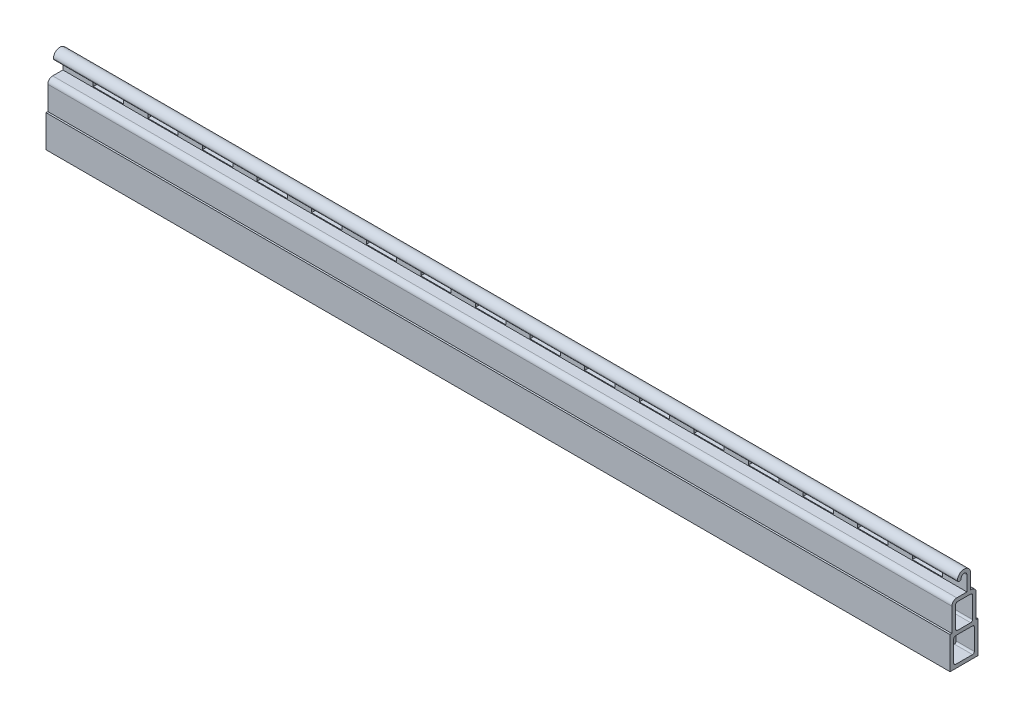
from build123d import *

# Parameters (mm, degrees)
BOSS_EXTRU_1_DEPTH      = 149
ESQUISSE2_W             = 5
ESQUISSE2_H             = 1
ENL_V_MAT_EXTRU_1_DEPTH = 10
ESQUISSE4_W             = 2.990234893
ESQUISSE4_H             = 4.26300154
ESQUISSE4_W_2           = 3.649620023
ESQUISSE4_H_2           = 4.293670615
BOSS_EXTRU_3_DEPTH      = 0.8
ESQUISSE5_W             = 0.460980277
ESQUISSE5_H             = 0.460980276
ESQUISSE5_W_2           = 0.460980276
BOSS_EXTRU_4_DEPTH      = 0.5


with BuildPart() as part:
    # Esquisse1 → Boss.-Extru.1 (new body)
    with BuildSketch(Plane(origin=(0, 0, 0), x_dir=(0, 0, -1), z_dir=(1, 0, 0))):
        with BuildLine():
            Line((-4.326223342, 6.7), (-4.326223342, 2.8))
            Line((-4.326223342, 2.8), (-4.626223342, 2.8))
            Line((-4.626223342, 2.8), (-4.626223342, -2.5))
            Line((-4.626223342, -2.5), (-0.026223342, -2.5))
            Line((-0.026223342, -2.5), (-0.026223342, 2.8))
            Line((-0.026223342, 2.8), (-0.326223342, 2.8))
            Line((-0.326223342, 2.8), (-0.326223342, 6.7))
            ThreePointArc((-0.326223342, 6.7), (-0.560537917, 7.265685425), (-1.126223342, 7.5))
            Line((-1.126223342, 7.5), (-1.246223342, 7.5))
            Line((-1.246223342, 7.5), (-1.246223342, 9.92))
            ThreePointArc((-1.246223342, 9.92), (-2.326223342, 11), (-3.406223342, 9.92))
            ThreePointArc((-3.406223342, 9.92), (-3.106223342, 9.62), (-2.806223342, 9.92))
            ThreePointArc((-2.806223342, 9.92), (-2.326223342, 10.4), (-1.846223342, 9.92))
            Line((-1.846223342, 9.92), (-1.846223342, 7.5))
            Line((-1.846223342, 7.5), (-3.526223342, 7.5))
            ThreePointArc((-3.526223342, 7.5), (-4.091908767, 7.265685425), (-4.326223342, 6.7))
        make_face()
        with BuildLine():
            Line((-3.726223342, 6.6), (-3.726223342, 3.1))
            ThreePointArc((-3.726223342, 3.1), (-3.638355377, 2.887867966), (-3.426223342, 2.8))
            Line((-3.426223342, 2.8), (-1.226223342, 2.8))
            ThreePointArc((-1.226223342, 2.8), (-1.014091308, 2.887867966), (-0.926223342, 3.1))
            Line((-0.926223342, 3.1), (-0.926223342, 6.6))
            ThreePointArc((-0.926223342, 6.6), (-1.014091308, 6.812132034), (-1.226223342, 6.9))
            Line((-1.226223342, 6.9), (-3.426223342, 6.9))
            ThreePointArc((-3.426223342, 6.9), (-3.638355377, 6.812132034), (-3.726223342, 6.6))
        make_face(mode=Mode.SUBTRACT)
        with BuildLine():
            Line((-4.026223342, 1.9), (-4.026223342, -1.6))
            ThreePointArc((-4.026223342, -1.6), (-3.938355377, -1.812132034), (-3.726223342, -1.9))
            Line((-3.726223342, -1.9), (-0.926223342, -1.9))
            ThreePointArc((-0.926223342, -1.9), (-0.714091308, -1.812132034), (-0.626223342, -1.6))
            Line((-0.626223342, -1.6), (-0.626223342, 1.9))
            ThreePointArc((-0.626223342, 1.9), (-0.714091308, 2.112132034), (-0.926223342, 2.2))
            Line((-0.926223342, 2.2), (-3.726223342, 2.2))
            ThreePointArc((-3.726223342, 2.2), (-3.938355377, 2.112132034), (-4.026223342, 1.9))
        make_face(mode=Mode.SUBTRACT)
    extrude(amount=BOSS_EXTRU_1_DEPTH)

    # Esquisse2 → Enlèv. mat.-Extru.1 (cut)
    with BuildSketch(Plane(origin=(0, 0, 1.246223342), x_dir=(-1, 0, 0), z_dir=(0, 0, -1))):
        with Locations((-16.5, 8.133641775)):
            Rectangle(ESQUISSE2_W, ESQUISSE2_H)
        with Locations((-25.5, 8.133641775)):
            Rectangle(ESQUISSE2_W, ESQUISSE2_H)
        with Locations((-34.5, 8.133641775)):
            Rectangle(ESQUISSE2_W, ESQUISSE2_H)
        with Locations((-43.5, 8.133641775)):
            Rectangle(ESQUISSE2_W, ESQUISSE2_H)
        with Locations((-52.5, 8.133641775)):
            Rectangle(ESQUISSE2_W, ESQUISSE2_H)
        with Locations((-61.5, 8.133641775)):
            Rectangle(ESQUISSE2_W, ESQUISSE2_H)
        with Locations((-70.5, 8.133641775)):
            Rectangle(ESQUISSE2_W, ESQUISSE2_H)
        with Locations((-79.5, 8.133641775)):
            Rectangle(ESQUISSE2_W, ESQUISSE2_H)
        with Locations((-88.5, 8.133641775)):
            Rectangle(ESQUISSE2_W, ESQUISSE2_H)
        with Locations((-97.5, 8.133641775)):
            Rectangle(ESQUISSE2_W, ESQUISSE2_H)
        with Locations((-106.5, 8.133641775)):
            Rectangle(ESQUISSE2_W, ESQUISSE2_H)
        with Locations((-115.5, 8.133641775)):
            Rectangle(ESQUISSE2_W, ESQUISSE2_H)
        with Locations((-124.5, 8.133641775)):
            Rectangle(ESQUISSE2_W, ESQUISSE2_H)
        with Locations((-133.5, 8.133641775)):
            Rectangle(ESQUISSE2_W, ESQUISSE2_H)
        with Locations((-142.5, 8.133641775)):
            Rectangle(ESQUISSE2_W, ESQUISSE2_H)
        with Locations((-7.5, 8.133641775)):
            Rectangle(ESQUISSE2_W, ESQUISSE2_H)
    extrude(amount=-ENL_V_MAT_EXTRU_1_DEPTH, mode=Mode.SUBTRACT)

    # Esquisse4 → Boss.-Extru.3 (add)
    with BuildSketch(Plane(origin=(3, 0, 0), x_dir=(0, 0, -1), z_dir=(1, 0, 0))):
        with Locations((-2.295750486, 4.817387417)):
            Rectangle(ESQUISSE4_W, ESQUISSE4_H)
        with Locations((-2.33408683, 0.155687892)):
            Rectangle(ESQUISSE4_W_2, ESQUISSE4_H_2)
    boss_extru_3 = extrude(amount=BOSS_EXTRU_3_DEPTH)

    # Symétrie1: Boss.-Extru.3 across plane
    add(boss_extru_3.mirror(Plane(origin=(74.5, 0, 0), x_dir=(0, 0, 1), z_dir=(1, 0, 0))))

    # Esquisse5 → Boss.-Extru.4 (add)
    with BuildSketch(Plane(origin=(0, 0, 0.026223342), x_dir=(-1, 0, 0), z_dir=(0, 0, -1))):
        with BuildLine():
            Line((-145.640037814, -1.642024067), (-146.46043865, 0.98556351))
            Line((-146.46043865, 0.98556351), (-145.98073105, 0.98556351))
            Line((-145.98073105, 0.98556351), (-145.541359223, -0.545755347))
            Line((-145.541359223, -0.545755347), (-145.408827394, -1.09533027))
            add(Edge.make_bspline(
                [(-145.408827394, -1.09533027), (-145.407655385, -1.089561723), (-145.404372808, -1.073405098), (-145.396705573, -1.042350052), (-145.387200652, -0.997266945), (-145.373082092, -0.938541209), (-145.355739381, -0.865863565), (-145.335803738, -0.779134452), (-145.312699162, -0.678492768), (-145.296007835, -0.606973631), (-145.28709979, -0.568804361)],
                knots=[0, 0, 0, 0, 0.261394749, 0.732117884, 1.420242552, 2.307348358, 3.414248811, 4.738505606, 6.259362921, 8, 8, 8, 8], degree=3))
            Line((-145.28709979, -0.568804361), (-144.898147681, 0.98556351))
            Line((-144.898147681, 0.98556351), (-144.421321207, 0.98556351))
            Line((-144.421321207, 0.98556351), (-144.034529944, -0.56016098))
            Line((-144.034529944, -0.56016098), (-143.925047128, -1.040588863))
            Line((-143.925047128, -1.040588863), (-143.788193608, -0.542153938))
            Line((-143.788193608, -0.542153938), (-143.345940655, 0.98556351))
            Line((-143.345940655, 0.98556351), (-142.864792491, 0.98556351))
            Line((-142.864792491, 0.98556351), (-143.64341699, -1.642024067))
            Line((-143.64341699, -1.642024067), (-144.179306562, -1.642024067))
            Line((-144.179306562, -1.642024067), (-144.554573318, -0.095579295))
            Line((-144.554573318, -0.095579295), (-144.662615571, 0.379086334))
            Line((-144.662615571, 0.379086334), (-145.146644861, -1.642024067))
            Line((-145.146644861, -1.642024067), (-145.640037814, -1.642024067))
        make_face()
        with BuildLine():
            Line((-142.090489683, -1.642024067), (-142.910890519, 0.98556351))
            Line((-142.910890519, 0.98556351), (-142.431182919, 0.98556351))
            Line((-142.431182919, 0.98556351), (-141.991811092, -0.545755347))
            Line((-141.991811092, -0.545755347), (-141.859279263, -1.09533027))
            add(Edge.make_bspline(
                [(-141.859279263, -1.09533027), (-141.858107254, -1.089561723), (-141.854824677, -1.073405098), (-141.847157441, -1.042350052), (-141.83765252, -0.997266945), (-141.823533961, -0.938541209), (-141.80619125, -0.865863565), (-141.786255607, -0.779134452), (-141.763151031, -0.678492768), (-141.746459704, -0.606973631), (-141.737551658, -0.568804361)],
                knots=[0, 0, 0, 0, 0.261394749, 0.732117884, 1.420242552, 2.307348358, 3.414248811, 4.738505606, 6.259362921, 8, 8, 8, 8], degree=3))
            Line((-141.737551658, -0.568804361), (-141.34859955, 0.98556351))
            Line((-141.34859955, 0.98556351), (-140.871773076, 0.98556351))
            Line((-140.871773076, 0.98556351), (-140.484981813, -0.56016098))
            Line((-140.484981813, -0.56016098), (-140.375498997, -1.040588863))
            Line((-140.375498997, -1.040588863), (-140.238645477, -0.542153938))
            Line((-140.238645477, -0.542153938), (-139.796392524, 0.98556351))
            Line((-139.796392524, 0.98556351), (-139.31524436, 0.98556351))
            Line((-139.31524436, 0.98556351), (-140.093868859, -1.642024067))
            Line((-140.093868859, -1.642024067), (-140.629758431, -1.642024067))
            Line((-140.629758431, -1.642024067), (-141.005025187, -0.095579295))
            Line((-141.005025187, -0.095579295), (-141.11306744, 0.379086334))
            Line((-141.11306744, 0.379086334), (-141.59709673, -1.642024067))
            Line((-141.59709673, -1.642024067), (-142.090489683, -1.642024067))
        make_face()
        with BuildLine():
            Line((-138.540941552, -1.642024067), (-139.361342388, 0.98556351))
            Line((-139.361342388, 0.98556351), (-138.881634787, 0.98556351))
            Line((-138.881634787, 0.98556351), (-138.442262961, -0.545755347))
            Line((-138.442262961, -0.545755347), (-138.309731132, -1.09533027))
            add(Edge.make_bspline(
                [(-138.309731132, -1.09533027), (-138.308559123, -1.089561723), (-138.305276546, -1.073405098), (-138.29760931, -1.042350052), (-138.288104389, -0.997266945), (-138.27398583, -0.938541209), (-138.256643119, -0.865863565), (-138.236707476, -0.779134452), (-138.2136029, -0.678492768), (-138.196911573, -0.606973631), (-138.188003527, -0.568804361)],
                knots=[0, 0, 0, 0, 0.261394749, 0.732117884, 1.420242552, 2.307348358, 3.414248811, 4.738505606, 6.259362921, 8, 8, 8, 8], degree=3))
            Line((-138.188003527, -0.568804361), (-137.799051419, 0.98556351))
            Line((-137.799051419, 0.98556351), (-137.322224945, 0.98556351))
            Line((-137.322224945, 0.98556351), (-136.935433681, -0.56016098))
            Line((-136.935433681, -0.56016098), (-136.825950866, -1.040588863))
            Line((-136.825950866, -1.040588863), (-136.689097346, -0.542153938))
            Line((-136.689097346, -0.542153938), (-136.246844393, 0.98556351))
            Line((-136.246844393, 0.98556351), (-135.765696229, 0.98556351))
            Line((-135.765696229, 0.98556351), (-136.544320728, -1.642024067))
            Line((-136.544320728, -1.642024067), (-137.0802103, -1.642024067))
            Line((-137.0802103, -1.642024067), (-137.455477056, -0.095579295))
            Line((-137.455477056, -0.095579295), (-137.563519309, 0.379086334))
            Line((-137.563519309, 0.379086334), (-138.047548599, -1.642024067))
            Line((-138.047548599, -1.642024067), (-138.540941552, -1.642024067))
        make_face()
        with Locations((-135.097274828, -1.411533929)):
            Rectangle(ESQUISSE5_W, ESQUISSE5_H)
        with BuildLine():
            add(Edge.make_bspline(
                [(-132.423589222, -1.319337874), (-132.463989636, -1.351112734), (-132.541825878, -1.412330812), (-132.660732627, -1.491568598), (-132.77565126, -1.556821476), (-132.888875542, -1.60671476), (-133.00251137, -1.643076888), (-133.118439338, -1.669012492), (-133.238472354, -1.685520913), (-133.320045835, -1.687247086), (-133.361395973, -1.688122095)],
                knots=[0, 0, 0, 0, 1.197047628, 2.306255791, 3.325459075, 4.272204958, 5.183179809, 6.100503351, 7.037132558, 8, 8, 8, 8], degree=3))
            add(Edge.make_bspline(
                [(-133.361395973, -1.688122095), (-133.395028012, -1.687337978), (-133.460264457, -1.685817016), (-133.555230586, -1.676731986), (-133.64414385, -1.660174367), (-133.727153965, -1.636932147), (-133.804845543, -1.608710196), (-133.875836901, -1.572135604), (-133.941097369, -1.529781322), (-133.9994684, -1.480509431), (-134.051208317, -1.426348754), (-134.097022815, -1.368745342), (-134.135277754, -1.306931358), (-134.167290291, -1.241935032), (-134.191974146, -1.172834747), (-134.209014306, -1.100096069), (-134.219268873, -1.023833759), (-134.220688659, -0.971953979), (-134.221412302, -0.945511681)],
                knots=[0, 0, 0, 0, 1.258692688, 2.441500428, 3.565802525, 4.638326649, 5.664695568, 6.653201623, 7.620115754, 8.570354797, 9.504485475, 10.41940588, 11.319425392, 12.219534596, 13.126122865, 14.058869773, 15.010636805, 16, 16, 16, 16], degree=3))
            add(Edge.make_bspline(
                [(-134.221412302, -0.945511681), (-134.220553002, -0.914223927), (-134.218862466, -0.852670249), (-134.202226859, -0.76276733), (-134.176595547, -0.676898902), (-134.139460901, -0.596430662), (-134.094404763, -0.52182317), (-134.04202504, -0.45432191), (-133.983841007, -0.393962013), (-133.917979699, -0.342722252), (-133.847313353, -0.298480251), (-133.772583845, -0.259094264), (-133.693462875, -0.225967851), (-133.638373916, -0.208714476), (-133.610613435, -0.200020139)],
                knots=[0, 0, 0, 0, 1.081160721, 2.127011708, 3.15154375, 4.173548368, 5.183333295, 6.160067524, 7.123185218, 8.075175306, 9.03822139, 10.004020623, 10.994184154, 12, 12, 12, 12], degree=3))
            add(Edge.make_bspline(
                [(-133.610613435, -0.200020139), (-133.587143802, -0.193988184), (-133.53502413, -0.180592852), (-133.447995942, -0.165149539), (-133.345329762, -0.148092054), (-133.271402248, -0.138760145), (-133.23174527, -0.133754224)],
                knots=[0, 0, 0, 0, 0.755247122, 1.677198421, 2.753978269, 4, 4, 4, 4], degree=3))
            add(Edge.make_bspline(
                [(-133.23174527, -0.133754224), (-133.190202112, -0.128286475), (-133.109945523, -0.117723415), (-132.993602846, -0.101512075), (-132.885806321, -0.083502509), (-132.786482861, -0.0645595), (-132.695463966, -0.046422063), (-132.613401486, -0.02605817), (-132.539538121, -0.005469853), (-132.49363641, 0.010109722), (-132.471848095, 0.017504929)],
                knots=[0, 0, 0, 0, 1.295688514, 2.50312072, 3.632112522, 4.674678079, 5.629835945, 6.501350263, 7.28863104, 8, 8, 8, 8], degree=3))
            add(Edge.make_bspline(
                [(-132.471848095, 0.017504929), (-132.471604414, 0.030229832), (-132.471163011, 0.053279667), (-132.470621519, 0.084015807), (-132.469563154, 0.107054187), (-132.469652041, 0.119784356), (-132.46968725, 0.1248269)],
                knots=[0, 0, 0, 0, 1.422721786, 2.577112132, 3.436380362, 4, 4, 4, 4], degree=3))
            add(Edge.make_bspline(
                [(-132.46968725, 0.1248269), (-132.47020969, 0.145001375), (-132.4712127, 0.183733549), (-132.475830537, 0.239684959), (-132.485317247, 0.290988224), (-132.498100771, 0.337812209), (-132.514324688, 0.380252524), (-132.53581647, 0.416967634), (-132.559298815, 0.450480852), (-132.578826824, 0.468705761), (-132.588533728, 0.477764924)],
                knots=[0, 0, 0, 0, 1.26154989, 2.42199954, 3.505345601, 4.517638791, 5.454101631, 6.334651141, 7.172195178, 8, 8, 8, 8], degree=3))
            add(Edge.make_bspline(
                [(-132.588533728, 0.477764924), (-132.602417369, 0.488978471), (-132.630806171, 0.511907552), (-132.679675046, 0.539147133), (-132.732063304, 0.564133862), (-132.789920152, 0.583499967), (-132.852382383, 0.598373911), (-132.919800928, 0.609104835), (-132.992001871, 0.615638528), (-133.041816664, 0.616391009), (-133.067521047, 0.616779289)],
                knots=[0, 0, 0, 0, 0.839762797, 1.717118621, 2.62848608, 3.573318781, 4.586191294, 5.652292021, 6.78858503, 8, 8, 8, 8], degree=3))
            add(Edge.make_bspline(
                [(-133.067521047, 0.616779289), (-133.091538232, 0.616534034), (-133.13769374, 0.61606271), (-133.204751848, 0.611587787), (-133.266821543, 0.604697479), (-133.324327468, 0.594596288), (-133.376521201, 0.581750727), (-133.424386428, 0.566625708), (-133.467257895, 0.548294581), (-133.518219396, 0.518849054), (-133.575565423, 0.471659329), (-133.631710242, 0.396932195), (-133.680991128, 0.306741343), (-133.702801561, 0.238159972), (-133.714333997, 0.20189704)],
                knots=[0, 0, 0, 0, 1.022193202, 1.964420342, 2.859404845, 3.679355848, 4.447752811, 5.145854219, 5.814144269, 6.427678132, 7.647232431, 8.943346363, 10.383770637, 12, 12, 12, 12], degree=3))
            Line((-133.714333997, 0.20189704), (-134.175314274, 0.247995067))
            add(Edge.make_bspline(
                [(-134.175314274, 0.247995067), (-134.164737005, 0.291250465), (-134.144312945, 0.374773995), (-134.0993731, 0.491265162), (-134.044980871, 0.59471901), (-133.981255851, 0.687070299), (-133.902926445, 0.766727101), (-133.811050611, 0.836845904), (-133.703230675, 0.895304045), (-133.581726969, 0.944904055), (-133.447492694, 0.984008054), (-133.302079213, 1.011801902), (-133.146657531, 1.028402353), (-133.039711874, 1.030554345), (-132.984688653, 1.031661538)],
                knots=[0, 0, 0, 0, 1.021253436, 1.971977998, 2.856928585, 3.699335328, 4.537187707, 5.410097588, 6.342486875, 7.343316183, 8.417452201, 9.545747471, 10.737294414, 12, 12, 12, 12], degree=3))
            add(Edge.make_bspline(
                [(-132.984688653, 1.031661538), (-132.930874074, 1.030720933), (-132.828316787, 1.028928371), (-132.682529795, 1.014867879), (-132.552360263, 0.990982889), (-132.438106583, 0.956382931), (-132.338788411, 0.914294835), (-132.253038682, 0.867978383), (-132.181258807, 0.815902013), (-132.122753018, 0.757732507), (-132.075817662, 0.692655191), (-132.037875157, 0.620654166), (-132.006184335, 0.541294901), (-131.992178552, 0.484696895), (-131.984937678, 0.455436192)],
                knots=[0, 0, 0, 0, 1.532418085, 2.920410157, 4.166262907, 5.295392887, 6.3126657, 7.233843889, 8.065362582, 8.82930282, 9.573337446, 10.341184706, 11.142406151, 12, 12, 12, 12], degree=3))
            add(Edge.make_bspline(
                [(-131.984937678, 0.455436192), (-131.98121452, 0.433149624), (-131.972648512, 0.381874097), (-131.967859252, 0.293650574), (-131.963072581, 0.184667757), (-131.962772493, 0.104910071), (-131.962608946, 0.061442112)],
                knots=[0, 0, 0, 0, 0.685842966, 1.577944182, 2.67997895, 4, 4, 4, 4], degree=3))
            Line((-131.962608946, 0.061442112), (-131.962608946, -0.501097882))
            add(Edge.make_bspline(
                [(-131.962608946, -0.501097882), (-131.962343903, -0.548156173), (-131.961838159, -0.637951192), (-131.961504517, -0.766409206), (-131.959524466, -0.882154752), (-131.955511795, -0.985612104), (-131.952197599, -1.076629726), (-131.948191463, -1.155435553), (-131.942476102, -1.221482489), (-131.934020113, -1.292803647), (-131.919276046, -1.372776445), (-131.894296677, -1.464533906), (-131.863940917, -1.554948604), (-131.837550938, -1.612938724), (-131.824314863, -1.642024067)],
                knots=[0, 0, 0, 0, 1.460752392, 2.787357723, 3.987454144, 5.053844556, 6.001073417, 6.814649835, 7.502887566, 8.058452826, 9.043678907, 10.023506295, 11.008675999, 12, 12, 12, 12], degree=3))
            Line((-131.824314863, -1.642024067), (-132.285295139, -1.642024067))
            add(Edge.make_bspline(
                [(-132.285295139, -1.642024067), (-132.302358283, -1.618463348), (-132.336458881, -1.57137738), (-132.374632717, -1.49213518), (-132.40606321, -1.408448355), (-132.417689162, -1.349336553), (-132.423589222, -1.319337874)],
                knots=[0, 0, 0, 0, 0.98283144, 1.964183219, 2.966842269, 4, 4, 4, 4], degree=3))
        make_face()
        with BuildLine():
            add(Edge.make_bspline(
                [(-132.46968725, -0.39737732), (-132.490011695, -0.404607388), (-132.532904083, -0.419865608), (-132.602085845, -0.438236389), (-132.677674657, -0.45841166), (-132.761045753, -0.475748976), (-132.85117269, -0.494109677), (-132.949014181, -0.510398465), (-133.053711735, -0.526216318), (-133.126087255, -0.535789011), (-133.16331851, -0.540713375)],
                knots=[0, 0, 0, 0, 0.729352295, 1.539213581, 2.419656264, 3.375381672, 4.41857158, 5.530700671, 6.729748458, 8, 8, 8, 8], degree=3))
            add(Edge.make_bspline(
                [(-133.16331851, -0.540713375), (-133.203947715, -0.546125034), (-133.278937838, -0.556113439), (-133.381295237, -0.574773429), (-133.46461249, -0.593792011), (-133.531187385, -0.613885578), (-133.585280357, -0.63757673), (-133.630087777, -0.667004826), (-133.669798106, -0.700010749), (-133.702058155, -0.738623733), (-133.728407972, -0.780105857), (-133.746161766, -0.824927679), (-133.758674666, -0.871363836), (-133.759842681, -0.903411368), (-133.760432025, -0.91958154)],
                knots=[0, 0, 0, 0, 1.886220442, 3.481434204, 4.78676141, 5.817751327, 6.678319802, 7.493641666, 8.277504993, 9.045791761, 9.800124555, 10.528599956, 11.257578043, 12, 12, 12, 12], degree=3))
            add(Edge.make_bspline(
                [(-133.760432025, -0.91958154), (-133.759074046, -0.944067491), (-133.756405078, -0.992192087), (-133.730122667, -1.060207131), (-133.689221173, -1.121724158), (-133.632339099, -1.176128685), (-133.559091982, -1.220083675), (-133.470838427, -1.251657721), (-133.368137912, -1.269860855), (-133.294966983, -1.272070302), (-133.256234847, -1.273239846)],
                knots=[0, 0, 0, 0, 0.849267971, 1.669148087, 2.501462232, 3.405991702, 4.385156294, 5.453560725, 6.652073551, 8, 8, 8, 8], degree=3))
            add(Edge.make_bspline(
                [(-133.256234847, -1.273239846), (-133.216511788, -1.272195781), (-133.138645658, -1.270149179), (-133.025510941, -1.248120209), (-132.918618771, -1.214839174), (-132.820376535, -1.166810388), (-132.7316088, -1.109927432), (-132.654763727, -1.045471615), (-132.589319071, -0.97518445), (-132.556515173, -0.922095259), (-132.540274855, -0.895812244)],
                knots=[0, 0, 0, 0, 1.124426932, 2.204129629, 3.254288104, 4.289056288, 5.293189312, 6.235005055, 7.126199027, 8, 8, 8, 8], degree=3))
            add(Edge.make_bspline(
                [(-132.540274855, -0.895812244), (-132.529323624, -0.87307514), (-132.505774596, -0.824182308), (-132.48724413, -0.738560732), (-132.473690304, -0.639843777), (-132.472489274, -0.569110962), (-132.471848095, -0.531349713)],
                knots=[0, 0, 0, 0, 0.806621552, 1.73452216, 2.790557523, 4, 4, 4, 4], degree=3))
            Line((-132.471848095, -0.531349713), (-132.46968725, -0.39737732))
        make_face(mode=Mode.SUBTRACT)
        Polygon((-130.026491783, -1.642024067), (-130.026491783, -0.766161542), (-131.593824724, -0.766161542), (-131.593824724, -0.305181265), (-129.8881977, 1.907524064), (-129.565511506, 1.907524064), (-129.565511506, -0.305181265), (-129.10453123, -0.305181265), (-129.10453123, -0.766161542), (-129.565511506, -0.766161542), (-129.565511506, -1.642024067), align=None)
        Polygon((-130.026491783, -0.305181265), (-130.026491783, 0.9898852), (-131.024802195, -0.305181265), align=None, mode=Mode.SUBTRACT)
        with Locations((-128.182570676, -1.411533929)):
            Rectangle(ESQUISSE5_W_2, ESQUISSE5_H)
        with BuildLine():
            Line((-127.05821097, -1.642024067), (-127.05821097, 0.570681261))
            Line((-127.05821097, 0.570681261), (-127.426995191, 0.570681261))
            Line((-127.426995191, 0.570681261), (-127.426995191, 0.98556351))
            Line((-127.426995191, 0.98556351), (-127.05821097, 0.98556351))
            Line((-127.05821097, 0.98556351), (-127.05821097, 1.252788014))
            add(Edge.make_bspline(
                [(-127.05821097, 1.252788014), (-127.057843305, 1.292197128), (-127.05715606, 1.365861276), (-127.047536998, 1.468061615), (-127.034211801, 1.554992038), (-127.017062189, 1.605646593), (-127.009231815, 1.628775053)],
                knots=[0, 0, 0, 0, 1.240410215, 2.318594698, 3.232283956, 4, 4, 4, 4], degree=3))
            add(Edge.make_bspline(
                [(-127.009231815, 1.628775053), (-126.996917211, 1.655442882), (-126.972195818, 1.70897817), (-126.918478418, 1.780906658), (-126.851549656, 1.843882577), (-126.773218771, 1.900085284), (-126.680579185, 1.946353329), (-126.572150372, 1.976857117), (-126.449813003, 1.996579682), (-126.36322597, 1.998638886), (-126.3177614, 1.999720119)],
                knots=[0, 0, 0, 0, 0.841887353, 1.690076852, 2.558213441, 3.472839095, 4.450413558, 5.515111839, 6.695250704, 8, 8, 8, 8], degree=3))
            add(Edge.make_bspline(
                [(-126.3177614, 1.999720119), (-126.286047574, 1.99916038), (-126.221068539, 1.99801352), (-126.121386464, 1.988474113), (-126.016669516, 1.97545237), (-125.945784356, 1.961507577), (-125.909361686, 1.954342373)],
                knots=[0, 0, 0, 0, 0.924505461, 1.89423605, 2.918002803, 4, 4, 4, 4], degree=3))
            Line((-125.909361686, 1.954342373), (-125.974907319, 1.561788856))
            add(Edge.make_bspline(
                [(-125.974907319, 1.561788856), (-126.019000209, 1.568509502), (-126.10448308, 1.581538816), (-126.190917466, 1.583761613), (-126.232768162, 1.58483787)],
                knots=[0, 0, 0, 0, 1.031619304, 2, 2, 2, 2], degree=3))
            add(Edge.make_bspline(
                [(-126.232768162, 1.58483787), (-126.263581715, 1.58405879), (-126.320841618, 1.58261105), (-126.399598977, 1.567551189), (-126.465129962, 1.543938667), (-126.517401926, 1.507317533), (-126.55561823, 1.455097253), (-126.579467712, 1.386975676), (-126.59531592, 1.303216792), (-126.59655678, 1.241596595), (-126.597230693, 1.20813055)],
                knots=[0, 0, 0, 0, 1.201235248, 2.232219511, 3.116244706, 3.901648155, 4.685036597, 5.598662795, 6.695829267, 8, 8, 8, 8], degree=3))
            Line((-126.597230693, 1.20813055), (-126.597230693, 0.98556351))
            Line((-126.597230693, 0.98556351), (-126.136250416, 0.98556351))
            Line((-126.136250416, 0.98556351), (-126.136250416, 0.570681261))
            Line((-126.136250416, 0.570681261), (-126.597230693, 0.570681261))
            Line((-126.597230693, 0.570681261), (-126.597230693, -1.642024067))
            Line((-126.597230693, -1.642024067), (-127.05821097, -1.642024067))
        make_face()
        with BuildLine():
            Line((-125.785473237, -1.642024067), (-125.785473237, 0.98556351))
            Line((-125.785473237, 0.98556351), (-125.370590988, 0.98556351))
            Line((-125.370590988, 0.98556351), (-125.370590988, 0.618940134))
            add(Edge.make_bspline(
                [(-125.370590988, 0.618940134), (-125.347383951, 0.6577179), (-125.304389802, 0.729558916), (-125.236580056, 0.824226933), (-125.172059837, 0.898371677), (-125.106927705, 0.95120272), (-125.041748252, 0.987766066), (-124.975192433, 1.012937953), (-124.905559359, 1.028928052), (-124.858077014, 1.030741345), (-124.833981134, 1.031661538)],
                knots=[0, 0, 0, 0, 1.517336028, 2.811068648, 3.907416798, 4.807929446, 5.613162482, 6.406966847, 7.191583018, 8, 8, 8, 8], degree=3))
            add(Edge.make_bspline(
                [(-124.833981134, 1.031661538), (-124.798318325, 1.030069964), (-124.726034071, 1.026844035), (-124.617728062, 1.002086414), (-124.508140624, 0.96455043), (-124.4383418, 0.92750107), (-124.402532407, 0.90849337)],
                knots=[0, 0, 0, 0, 0.943117096, 1.911585642, 2.928565726, 4, 4, 4, 4], degree=3))
            Line((-124.402532407, 0.90849337), (-124.546588743, 0.508737036))
            add(Edge.make_bspline(
                [(-124.546588743, 0.508737036), (-124.57159851, 0.525365605), (-124.61983239, 0.55743549), (-124.69717316, 0.591400929), (-124.774451662, 0.613079307), (-124.826403563, 0.615558411), (-124.851988176, 0.616779289)],
                knots=[0, 0, 0, 0, 1.093324321, 2.108587182, 3.068540977, 4, 4, 4, 4], degree=3))
            add(Edge.make_bspline(
                [(-124.851988176, 0.616779289), (-124.874181082, 0.615651853), (-124.91800015, 0.613425774), (-124.982025262, 0.59613536), (-125.042261721, 0.567558947), (-125.098663092, 0.528576101), (-125.148826161, 0.479301505), (-125.192853472, 0.421674207), (-125.228431808, 0.354681974), (-125.244769574, 0.305659147), (-125.253185074, 0.280407743)],
                knots=[0, 0, 0, 0, 0.946345552, 1.868524143, 2.808299705, 3.780481321, 4.780563855, 5.797153696, 6.865325266, 8, 8, 8, 8], degree=3))
            add(Edge.make_bspline(
                [(-125.253185074, 0.280407743), (-125.264175397, 0.23950063), (-125.286488947, 0.1564473), (-125.307913589, 0.027213545), (-125.322399226, -0.107491608), (-125.323785224, -0.199258848), (-125.32449296, -0.246118167)],
                knots=[0, 0, 0, 0, 0.953038166, 1.934944501, 2.945515915, 4, 4, 4, 4], degree=3))
            Line((-125.32449296, -0.246118167), (-125.32449296, -1.642024067))
            Line((-125.32449296, -1.642024067), (-125.785473237, -1.642024067))
        make_face()
    extrude(amount=BOSS_EXTRU_4_DEPTH)


solid = part.part
